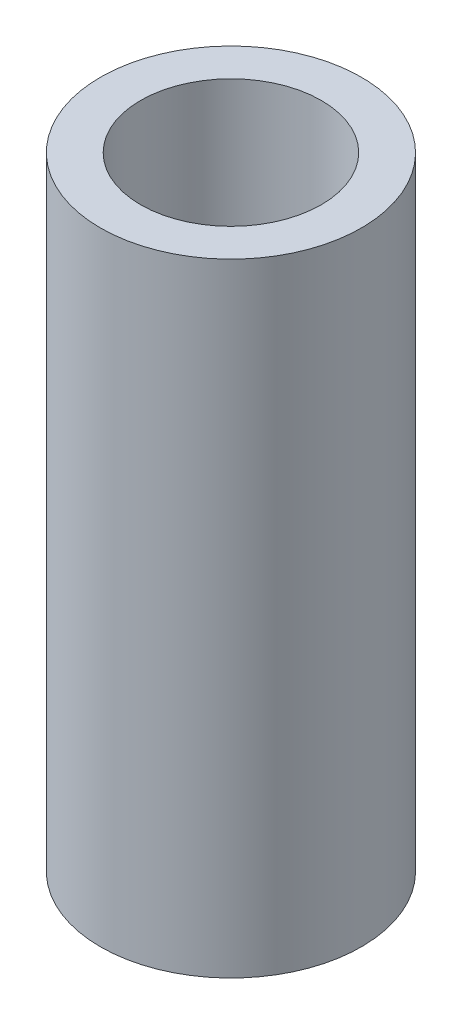
from build123d import *

# Parameters (mm, degrees)
SKETCH1_R           = 3.25
SKETCH1_R_2         = 2.25
BOSS_EXTRUDE1_DEPTH = 15.5


with BuildPart() as part:
    # Sketch1 → Boss-Extrude1 (new body)
    with BuildSketch(Plane(origin=(0, 0, 0), x_dir=(1, 0, 0), z_dir=(0, 1, 0))):
        Circle(SKETCH1_R)
        Circle(SKETCH1_R_2, mode=Mode.SUBTRACT)
    extrude(amount=BOSS_EXTRUDE1_DEPTH)


solid = part.part
